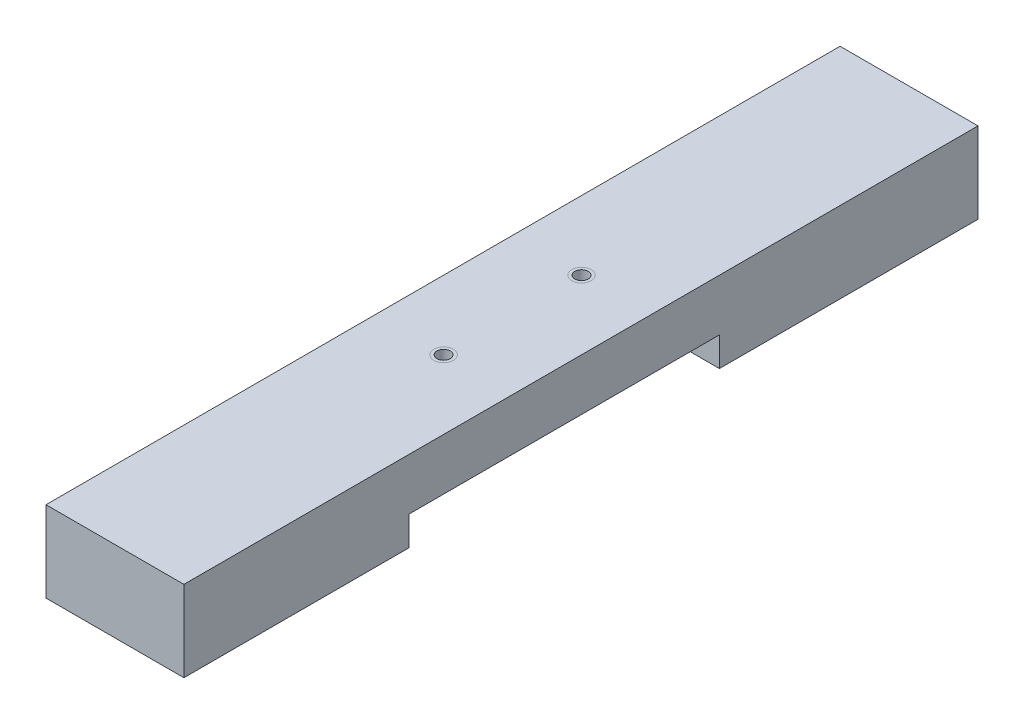
from build123d import *

# Parameters (mm, degrees)
SKETCH1_W           = 101.6
SKETCH1_H           = 59.6
BOSS_EXTRUDE1_DEPTH = 585.0001
SKETCH2_W           = 228.6
SKETCH2_H           = 21.5
CUT_EXTRUDE1_DEPTH  = 102.6
CUT_EXTRUDE4_DEPTH  = 6.35
CUT_EXTRUDE5_DEPTH  = 25.4
SKETCH6_R           = 4.934351916
CUT_EXTRUDE6_DEPTH  = 39.1


with BuildPart() as part:
    # Sketch1 → Boss-Extrude1 (new body)
    with BuildSketch(Plane.XY):
        with Locations((50.8, 29.8)):
            Rectangle(SKETCH1_W, SKETCH1_H)
    extrude(amount=BOSS_EXTRUDE1_DEPTH)

    # Sketch2 → Cut-Extrude1 (cut, through all)
    with BuildSketch(Plane.ZY):
        with Locations((304.8, 10.75)):
            Rectangle(SKETCH2_W, SKETCH2_H)
    extrude(amount=-CUT_EXTRUDE1_DEPTH, mode=Mode.SUBTRACT)

    # Sketch5 → Cut-Extrude4 (cut)
    with BuildSketch(Plane.ZY):
        with BuildLine():
            ThreePointArc((170, 31.35), (168.25, 29.6), (170, 27.85))
            ThreePointArc((170, 27.85), (171.75, 29.6), (170, 31.35))
        make_face()
        with BuildLine():
            ThreePointArc((110, 27.85), (111.75, 29.6), (110, 31.35))
            ThreePointArc((110, 31.35), (108.25, 29.6), (110, 27.85))
        make_face()
        with BuildLine():
            ThreePointArc((50, 27.85), (51.75, 29.6), (50, 31.35))
            ThreePointArc((50, 31.35), (48.25, 29.6), (50, 27.85))
        make_face()
        with BuildLine():
            ThreePointArc((530, 27.85), (531.75, 29.6), (530, 31.35))
            ThreePointArc((530, 31.35), (528.25, 29.6), (530, 27.85))
        make_face()
        with BuildLine():
            ThreePointArc((470, 27.85), (471.75, 29.6), (470, 31.35))
            ThreePointArc((470, 31.35), (468.25, 29.6), (470, 27.85))
        make_face()
        with BuildLine():
            ThreePointArc((410, 27.85), (411.75, 29.6), (410, 31.35))
            ThreePointArc((410, 31.35), (408.25, 29.6), (410, 27.85))
        make_face()
        with BuildLine():
            ThreePointArc((350, 27.85), (351.75, 29.6), (350, 31.35))
            ThreePointArc((350, 31.35), (348.25, 29.6), (350, 27.85))
        make_face()
        with BuildLine():
            ThreePointArc((290, 27.85), (291.75, 29.6), (290, 31.35))
            ThreePointArc((290, 31.35), (288.25, 29.6), (290, 27.85))
        make_face()
        with BuildLine():
            ThreePointArc((230, 27.85), (231.75, 29.6), (230, 31.35))
            ThreePointArc((230, 31.35), (228.25, 29.6), (230, 27.85))
        make_face()
    extrude(amount=-CUT_EXTRUDE4_DEPTH, mode=Mode.SUBTRACT)

    # Sketch5_3 → Cut-Extrude5 (cut)
    with BuildSketch(Plane.ZY):
        with BuildLine():
            ThreePointArc((562.7, 6.6), (566, 3.3), (569.3, 6.6))
            ThreePointArc((569.3, 6.6), (566, 9.9), (562.7, 6.6))
        make_face()
        with BuildLine():
            ThreePointArc((582.3, 6.6), (579, 9.9), (575.7, 6.6))
            ThreePointArc((575.7, 6.6), (579, 3.3), (582.3, 6.6))
        make_face()
        with BuildLine():
            ThreePointArc((575.7, 52.6), (579, 49.3), (582.3, 52.6))
            ThreePointArc((582.3, 52.6), (579, 55.9), (575.7, 52.6))
        make_face()
        with BuildLine():
            ThreePointArc((562.7, 52.6), (566, 49.3), (569.3, 52.6))
            ThreePointArc((569.3, 52.6), (566, 55.9), (562.7, 52.6))
        make_face()
        with BuildLine():
            ThreePointArc((6.7, 6.6), (10, 3.3), (13.3, 6.6))
            ThreePointArc((13.3, 6.6), (10, 9.9), (6.7, 6.6))
        make_face()
        with BuildLine():
            ThreePointArc((6.7, 52.6), (10, 49.3), (13.3, 52.6))
            ThreePointArc((13.3, 52.6), (10, 55.9), (6.7, 52.6))
        make_face()
    extrude(amount=-CUT_EXTRUDE5_DEPTH, mode=Mode.SUBTRACT)

    # Sketch6 → Cut-Extrude6 (cut, through all)
    with BuildSketch(Plane.XZ.offset(-21.5)):
        with Locations((50.8, 342.9)):
            Circle(SKETCH6_R)
        with Locations((50.8, 241.3)):
            Circle(SKETCH6_R)
    extrude(amount=-CUT_EXTRUDE6_DEPTH, mode=Mode.SUBTRACT)


solid = part.part
